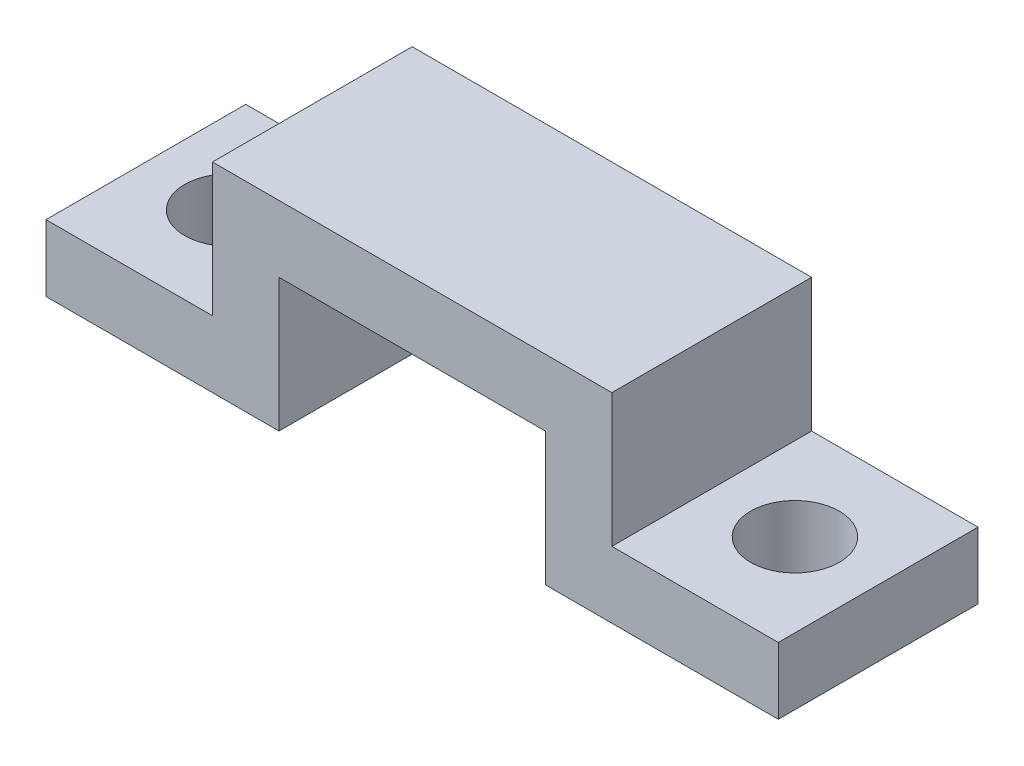
from build123d import *

# Parameters (mm, degrees)
RESSALTO_EXTRUS_O1_DEPTH = 9
ESBO_O2_R                = 2
CORTE_EXTRUS_O1_DEPTH    = 10


with BuildPart() as part:
    # Esboço1 → Ressalto-extrusão1 (new body)
    with BuildSketch(Plane.XY):
        Polygon((0, 0), (10.5, 0), (10.5, 6), (22.5, 6), (22.5, 0), (33, 0), (33, 3), (25.5, 3), (25.5, 9), (7.5, 9), (7.5, 3), (0, 3), align=None)
    extrude(amount=RESSALTO_EXTRUS_O1_DEPTH)

    # Esboço2 → Corte-extrusão1 (cut)
    with BuildSketch(Plane(origin=(0, 3, 0), x_dir=(1, 0, 0), z_dir=(0, 1, 0))):
        with Locations((29.25, -4.5)):
            Circle(ESBO_O2_R)
        with Locations((3.75, -4.5)):
            Circle(ESBO_O2_R)
    extrude(amount=-CORTE_EXTRUS_O1_DEPTH, mode=Mode.SUBTRACT)


solid = part.part
